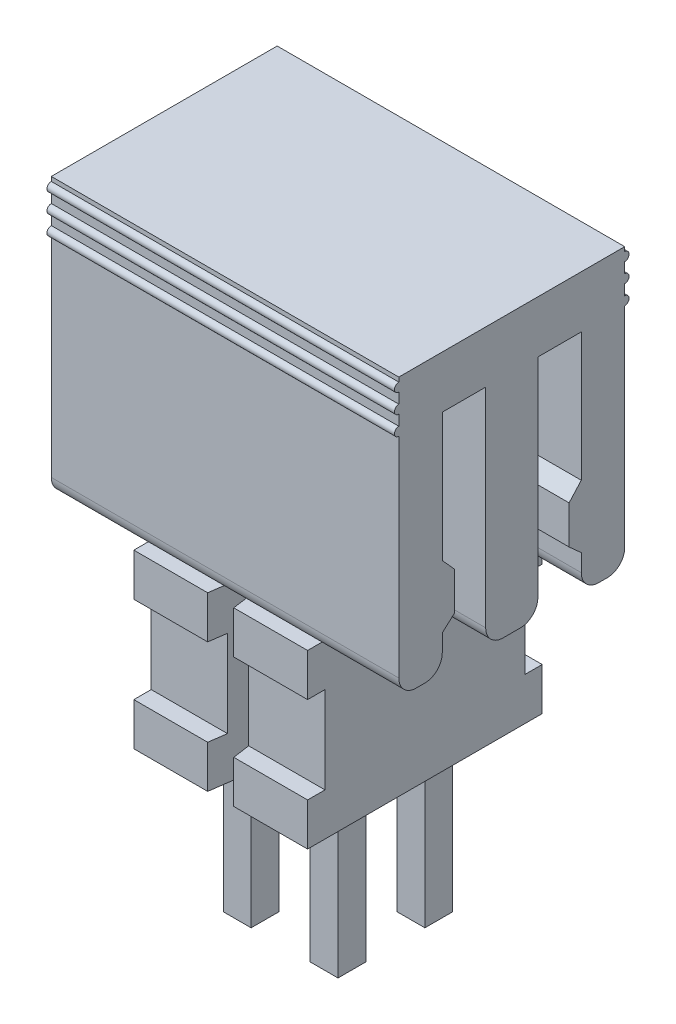
from build123d import *
from OCP.BRepFilletAPI import BRepFilletAPI_MakeChamfer

# Parameters (mm, degrees)
SKETCH1_W                      = 2.54
SKETCH1_H                      = 3.429
BASE_DEPTH                     = 2.5146
SNAP_GROOVE_DEPTH              = 4.297821009
SKETCH3_W                      = 0.254
SKETCH3_H                      = 1.27
SIDE_GROOVE_DEPTH              = 4.96412959
SKETCH4_W                      = 0.4064
SKETCH4_H                      = 3.048
PIN_POST_DEPTH                 = 0.2032
POST_TIP_SIZE                  = 0.2286
POST_TIP_SIZE2                 = 0.131982272
POST_PATTERN_COUNT             = 2
POST_PATTERN_PITCH             = 1.27
POST_TIP_OF_POST_PATTERN_SIZE  = 0.2286
POST_TIP_OF_POST_PATTERN_SIZE2 = 0.131982272
SKETCH5_W                      = 0.4064
SKETCH5_H                      = 2.286
TH_TAIL_DEPTH                  = 0.2032
TH_TAIL_PATTERN_COUNT          = 2
TH_TAIL_PATTERN_PITCH          = 1.27
EXTRUDE_P_DEPTH                = 2.54
PPP_25_CUT_DEPTH               = 5.08


with BuildPart() as part:
    # Sketch1 → Base (new body)
    with BuildSketch(Plane(origin=(0, 0, 0), x_dir=(1, 0, 0), z_dir=(0, 1, 0))):
        Rectangle(SKETCH1_W, SKETCH1_H)
    extrude(amount=BASE_DEPTH)

    # Sketch2 → Snap Groove (cut, through all)
    with BuildSketch(Plane(origin=(0, 2.5146, 0), x_dir=(-1, 0, 0), z_dir=(0, 1, 0))):
        Polygon((0.1905, 1.7145), (0.1016, 1.0795), (-0.1016, 1.0795), (-0.1905, 1.7145), align=None)
        Polygon((-0.1905, -1.7145), (0.1905, -1.7145), (0.1016, -1.0795), (-0.1016, -1.0795), align=None)
    extrude(amount=-SNAP_GROOVE_DEPTH, mode=Mode.SUBTRACT)

    # Sketch3 → Side Groove (cut, through all)
    with BuildSketch(Plane.ZY.offset(1.27)):
        with Locations((-1.5875, 1.2573)):
            Rectangle(SKETCH3_W, SKETCH3_H)
        with Locations((1.5875, 1.2573)):
            Rectangle(SKETCH3_W, SKETCH3_H)
    extrude(amount=-SIDE_GROOVE_DEPTH, mode=Mode.SUBTRACT)

    # Sketch4 → Pin Post (add, symmetric)
    with BuildSketch(Plane.ZY.offset(0.635)):
        with Locations((0.635, 4.0386)):
            Rectangle(SKETCH4_W, SKETCH4_H)
        with Locations((-0.635, 4.0386)):
            Rectangle(SKETCH4_W, SKETCH4_H)
    pin_post = extrude(amount=PIN_POST_DEPTH, both=True)

    # Post Tip: one chamfer whose edges measure the first distance from different faces: ONE call of the kernel's chamfer builder (chamfer() names one face for all edges)
    post_tip_edges_1 = [part.edges().sort_by_distance(p)[0] for p in [
        (-0.4318, 5.5626, 0.635),
    ]]
    post_tip_side_1 = [part.faces().sort_by_distance(p)[0] for p in [
        (-0.4318, 4.0386, 0.635),
    ]]
    post_tip_edges_2 = [part.edges().sort_by_distance(p)[0] for p in [
        (-0.635, 5.5626, 0.8382),
    ]]
    post_tip_side_2 = [part.faces().sort_by_distance(p)[0] for p in [
        (-0.635, 4.0386, 0.8382),
    ]]
    post_tip_edges_3 = [part.edges().sort_by_distance(p)[0] for p in [
        (-0.635, 5.5626, 0.4318),
    ]]
    post_tip_side_3 = [part.faces().sort_by_distance(p)[0] for p in [
        (-0.635, 4.0386, 0.4318),
    ]]
    post_tip_edges_4 = [part.edges().sort_by_distance(p)[0] for p in [
        (-0.8382, 5.5626, 0.635),
    ]]
    post_tip_side_4 = [part.faces().sort_by_distance(p)[0] for p in [
        (-0.8382, 4.0386, 0.635),
    ]]
    post_tip_edges_5 = [part.edges().sort_by_distance(p)[0] for p in [
        (-0.4318, 5.5626, -0.635),
    ]]
    post_tip_side_5 = [part.faces().sort_by_distance(p)[0] for p in [
        (-0.4318, 4.0386, -0.635),
    ]]
    post_tip_edges_6 = [part.edges().sort_by_distance(p)[0] for p in [
        (-0.635, 5.5626, -0.4318),
    ]]
    post_tip_side_6 = [part.faces().sort_by_distance(p)[0] for p in [
        (-0.635, 4.0386, -0.4318),
    ]]
    post_tip_edges_7 = [part.edges().sort_by_distance(p)[0] for p in [
        (-0.635, 5.5626, -0.8382),
    ]]
    post_tip_side_7 = [part.faces().sort_by_distance(p)[0] for p in [
        (-0.635, 4.0386, -0.8382),
    ]]
    post_tip_edges_8 = [part.edges().sort_by_distance(p)[0] for p in [
        (-0.8382, 5.5626, -0.635),
    ]]
    post_tip_side_8 = [part.faces().sort_by_distance(p)[0] for p in [
        (-0.8382, 4.0386, -0.635),
    ]]
    post_tip = BRepFilletAPI_MakeChamfer(part.part.solid().wrapped)
    for e in post_tip_edges_1:
        post_tip.Add(POST_TIP_SIZE, POST_TIP_SIZE2, e.wrapped, post_tip_side_1[0].wrapped)  # the first distance lies on this face
    for e in post_tip_edges_2:
        post_tip.Add(POST_TIP_SIZE, POST_TIP_SIZE2, e.wrapped, post_tip_side_2[0].wrapped)  # the first distance lies on this face
    for e in post_tip_edges_3:
        post_tip.Add(POST_TIP_SIZE, POST_TIP_SIZE2, e.wrapped, post_tip_side_3[0].wrapped)  # the first distance lies on this face
    for e in post_tip_edges_4:
        post_tip.Add(POST_TIP_SIZE, POST_TIP_SIZE2, e.wrapped, post_tip_side_4[0].wrapped)  # the first distance lies on this face
    for e in post_tip_edges_5:
        post_tip.Add(POST_TIP_SIZE, POST_TIP_SIZE2, e.wrapped, post_tip_side_5[0].wrapped)  # the first distance lies on this face
    for e in post_tip_edges_6:
        post_tip.Add(POST_TIP_SIZE, POST_TIP_SIZE2, e.wrapped, post_tip_side_6[0].wrapped)  # the first distance lies on this face
    for e in post_tip_edges_7:
        post_tip.Add(POST_TIP_SIZE, POST_TIP_SIZE2, e.wrapped, post_tip_side_7[0].wrapped)  # the first distance lies on this face
    for e in post_tip_edges_8:
        post_tip.Add(POST_TIP_SIZE, POST_TIP_SIZE2, e.wrapped, post_tip_side_8[0].wrapped)  # the first distance lies on this face
    add(Compound.cast(post_tip.Shape()), mode=Mode.REPLACE)

    # Post Pattern: Pin Post ×2
    with Locations(*[(i * POST_PATTERN_PITCH, 0, 0) for i in range(1, POST_PATTERN_COUNT)]):
        add(pin_post)

    # Post Tip of Post Pattern: one chamfer whose edges measure the first distance from different faces: ONE call of the kernel's chamfer builder (chamfer() names one face for all edges)
    post_tip_of_post_pattern_edges_1 = [part.edges().sort_by_distance(p)[0] for p in [
        (0.8382, 5.5626, 0.635),
    ]]
    post_tip_of_post_pattern_side_1 = [part.faces().sort_by_distance(p)[0] for p in [
        (0.8382, 4.0386, 0.635),
    ]]
    post_tip_of_post_pattern_edges_2 = [part.edges().sort_by_distance(p)[0] for p in [
        (0.635, 5.5626, 0.8382),
    ]]
    post_tip_of_post_pattern_side_2 = [part.faces().sort_by_distance(p)[0] for p in [
        (0.635, 4.0386, 0.8382),
    ]]
    post_tip_of_post_pattern_edges_3 = [part.edges().sort_by_distance(p)[0] for p in [
        (0.635, 5.5626, 0.4318),
    ]]
    post_tip_of_post_pattern_side_3 = [part.faces().sort_by_distance(p)[0] for p in [
        (0.635, 4.0386, 0.4318),
    ]]
    post_tip_of_post_pattern_edges_4 = [part.edges().sort_by_distance(p)[0] for p in [
        (0.4318, 5.5626, 0.635),
    ]]
    post_tip_of_post_pattern_side_4 = [part.faces().sort_by_distance(p)[0] for p in [
        (0.4318, 4.0386, 0.635),
    ]]
    post_tip_of_post_pattern_edges_5 = [part.edges().sort_by_distance(p)[0] for p in [
        (0.8382, 5.5626, -0.635),
    ]]
    post_tip_of_post_pattern_side_5 = [part.faces().sort_by_distance(p)[0] for p in [
        (0.8382, 4.0386, -0.635),
    ]]
    post_tip_of_post_pattern_edges_6 = [part.edges().sort_by_distance(p)[0] for p in [
        (0.635, 5.5626, -0.4318),
    ]]
    post_tip_of_post_pattern_side_6 = [part.faces().sort_by_distance(p)[0] for p in [
        (0.635, 4.0386, -0.4318),
    ]]
    post_tip_of_post_pattern_edges_7 = [part.edges().sort_by_distance(p)[0] for p in [
        (0.635, 5.5626, -0.8382),
    ]]
    post_tip_of_post_pattern_side_7 = [part.faces().sort_by_distance(p)[0] for p in [
        (0.635, 4.0386, -0.8382),
    ]]
    post_tip_of_post_pattern_edges_8 = [part.edges().sort_by_distance(p)[0] for p in [
        (0.4318, 5.5626, -0.635),
    ]]
    post_tip_of_post_pattern_side_8 = [part.faces().sort_by_distance(p)[0] for p in [
        (0.4318, 4.0386, -0.635),
    ]]
    post_tip_of_post_pattern = BRepFilletAPI_MakeChamfer(part.part.solid().wrapped)
    for e in post_tip_of_post_pattern_edges_1:
        post_tip_of_post_pattern.Add(POST_TIP_OF_POST_PATTERN_SIZE, POST_TIP_OF_POST_PATTERN_SIZE2, e.wrapped, post_tip_of_post_pattern_side_1[0].wrapped)  # the first distance lies on this face
    for e in post_tip_of_post_pattern_edges_2:
        post_tip_of_post_pattern.Add(POST_TIP_OF_POST_PATTERN_SIZE, POST_TIP_OF_POST_PATTERN_SIZE2, e.wrapped, post_tip_of_post_pattern_side_2[0].wrapped)  # the first distance lies on this face
    for e in post_tip_of_post_pattern_edges_3:
        post_tip_of_post_pattern.Add(POST_TIP_OF_POST_PATTERN_SIZE, POST_TIP_OF_POST_PATTERN_SIZE2, e.wrapped, post_tip_of_post_pattern_side_3[0].wrapped)  # the first distance lies on this face
    for e in post_tip_of_post_pattern_edges_4:
        post_tip_of_post_pattern.Add(POST_TIP_OF_POST_PATTERN_SIZE, POST_TIP_OF_POST_PATTERN_SIZE2, e.wrapped, post_tip_of_post_pattern_side_4[0].wrapped)  # the first distance lies on this face
    for e in post_tip_of_post_pattern_edges_5:
        post_tip_of_post_pattern.Add(POST_TIP_OF_POST_PATTERN_SIZE, POST_TIP_OF_POST_PATTERN_SIZE2, e.wrapped, post_tip_of_post_pattern_side_5[0].wrapped)  # the first distance lies on this face
    for e in post_tip_of_post_pattern_edges_6:
        post_tip_of_post_pattern.Add(POST_TIP_OF_POST_PATTERN_SIZE, POST_TIP_OF_POST_PATTERN_SIZE2, e.wrapped, post_tip_of_post_pattern_side_6[0].wrapped)  # the first distance lies on this face
    for e in post_tip_of_post_pattern_edges_7:
        post_tip_of_post_pattern.Add(POST_TIP_OF_POST_PATTERN_SIZE, POST_TIP_OF_POST_PATTERN_SIZE2, e.wrapped, post_tip_of_post_pattern_side_7[0].wrapped)  # the first distance lies on this face
    for e in post_tip_of_post_pattern_edges_8:
        post_tip_of_post_pattern.Add(POST_TIP_OF_POST_PATTERN_SIZE, POST_TIP_OF_POST_PATTERN_SIZE2, e.wrapped, post_tip_of_post_pattern_side_8[0].wrapped)  # the first distance lies on this face
    add(Compound.cast(post_tip_of_post_pattern.Shape()), mode=Mode.REPLACE)

    # Sketch5 → TH Tail (add, symmetric)
    with BuildSketch(Plane.ZY.offset(0.635)):
        with Locations((0.635, -1.143)):
            Rectangle(SKETCH5_W, SKETCH5_H)
        with Locations((-0.635, -1.143)):
            Rectangle(SKETCH5_W, SKETCH5_H)
    th_tail = extrude(amount=TH_TAIL_DEPTH, both=True)

    # TH Tail Pattern: TH Tail ×2
    with Locations(*[(i * TH_TAIL_PATTERN_PITCH, 0, 0) for i in range(1, TH_TAIL_PATTERN_COUNT)]):
        add(th_tail)

    # Sketch24 → Extrude P (add, symmetric)
    with BuildSketch(Plane(origin=(0, 0, 0), x_dir=(0, 0, -1), z_dir=(1, 0, 0))):
        with BuildLine():
            Line((-1.016, 5.8166), (-1.016, 3.938958744))
            Line((-1.016, 3.938958744), (-0.8382, 3.741491839))
            Line((-0.8382, 3.741491839), (-0.8382, 3.182691839))
            Line((-0.8382, 3.182691839), (-1.016, 3.0226))
            Line((-1.016, 3.0226), (-1.016, 2.7686))
            ThreePointArc((-1.016, 2.7686), (-1.090394878, 2.588994878), (-1.27, 2.5146))
            Line((-1.27, 2.5146), (-1.397, 2.5146))
            ThreePointArc((-1.397, 2.5146), (-1.576605122, 2.588994878), (-1.651, 2.7686))
            Line((-1.651, 2.7686), (-1.651, 5.8166))
            Line((-1.651, 5.8166), (-2.921, 5.8166))
            Line((-2.921, 5.8166), (-2.921, 6.5786))
            Line((-2.921, 6.5786), (2.921, 6.5786))
            Line((2.921, 6.5786), (2.921, 5.8166))
            Line((2.921, 5.8166), (1.651, 5.8166))
            Line((1.651, 5.8166), (1.651, 2.7686))
            ThreePointArc((1.651, 2.7686), (1.576605122, 2.588994878), (1.397, 2.5146))
            Line((1.397, 2.5146), (1.27, 2.5146))
            ThreePointArc((1.27, 2.5146), (1.090394878, 2.588994878), (1.016, 2.7686))
            Line((1.016, 2.7686), (1.016, 3.0226))
            Line((1.016, 3.0226), (0.8382, 3.182691839))
            Line((0.8382, 3.182691839), (0.8382, 3.741491839))
            Line((0.8382, 3.741491839), (1.016, 3.938958744))
            Line((1.016, 3.938958744), (1.016, 5.8166))
            Line((1.016, 5.8166), (0.381, 5.8166))
            Line((0.381, 5.8166), (0.381, 2.7686))
            ThreePointArc((0.381, 2.7686), (0.306605122, 2.588994878), (0.127, 2.5146))
            Line((0.127, 2.5146), (-0.127, 2.5146))
            ThreePointArc((-0.127, 2.5146), (-0.306605122, 2.588994878), (-0.381, 2.7686))
            Line((-0.381, 2.7686), (-0.381, 5.8166))
            Line((-0.381, 5.8166), (-1.016, 5.8166))
        make_face()
    extrude(amount=EXTRUDE_P_DEPTH, both=True)

    # Sketch43 → PPP-25 cut (cut)
    with BuildSketch(Plane(origin=(2.54, 0, 0), x_dir=(0, 0, -1), z_dir=(1, 0, 0))):
        with BuildLine():
            Line((-1.651, 5.8293), (-1.651, 5.8166))
            Line((-1.651, 5.8166), (-2.921, 5.8166))
            Line((-2.921, 5.8166), (-2.921, 6.5786))
            Line((-2.921, 6.5786), (-1.651, 6.5786))
            Line((-1.651, 6.5786), (-1.651, 6.5151))
            ThreePointArc((-1.651, 6.5151), (-1.7145, 6.4516), (-1.651, 6.3881))
            Line((-1.651, 6.3881), (-1.651, 6.2357))
            ThreePointArc((-1.651, 6.2357), (-1.7145, 6.1722), (-1.651, 6.1087))
            Line((-1.651, 6.1087), (-1.651, 5.9563))
            ThreePointArc((-1.651, 5.9563), (-1.7145, 5.8928), (-1.651, 5.8293))
        make_face()
        with BuildLine():
            Line((1.651, 6.3881), (1.651, 6.2357))
            ThreePointArc((1.651, 6.2357), (1.7145, 6.1722), (1.651, 6.1087))
            Line((1.651, 6.1087), (1.651, 5.9563))
            ThreePointArc((1.651, 5.9563), (1.7145, 5.8928), (1.651, 5.8293))
            Line((1.651, 5.8293), (1.651, 5.8166))
            Line((1.651, 5.8166), (2.921, 5.8166))
            Line((2.921, 5.8166), (2.921, 6.5786))
            Line((2.921, 6.5786), (1.651, 6.5786))
            Line((1.651, 6.5786), (1.651, 6.5151))
            ThreePointArc((1.651, 6.5151), (1.7145, 6.4516), (1.651, 6.3881))
        make_face()
    extrude(amount=-PPP_25_CUT_DEPTH, mode=Mode.SUBTRACT)


solid = part.part
